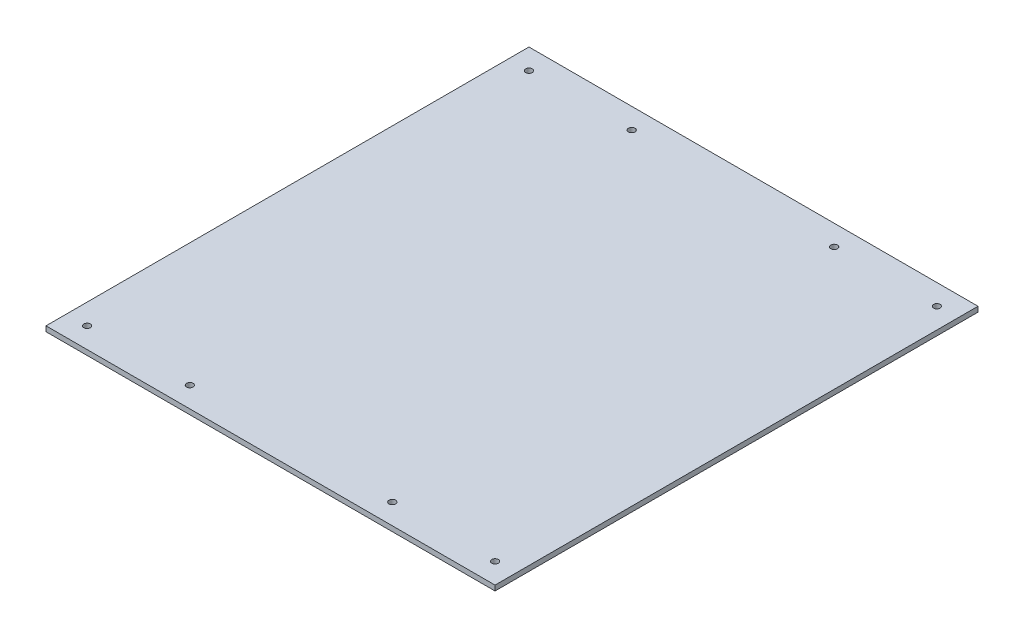
from build123d import *

# Parameters (mm, degrees)
SKETCH1_W                = 437
SKETCH1_H                = 470
BOSS_EXTRUDE1_DEPTH      = 5
M6_CLEARANCE_HOLE1_D     = 6.4
M6_CLEARANCE_HOLE1_DEPTH = 10
M6_CLEARANCE_HOLE1_TIP   = 1.922753981


with BuildPart() as part:
    # Sketch1 → Boss-Extrude1 (new body)
    with BuildSketch(Plane(origin=(0, 0, 0), x_dir=(1, 0, 0), z_dir=(0, 1, 0))):
        Rectangle(SKETCH1_W, SKETCH1_H)
    extrude(amount=BOSS_EXTRUDE1_DEPTH)

    # M6 Clearance Hole1
    with Locations(Plane(origin=(0, 5, 0), x_dir=(1, 0, 0), z_dir=(0, 1, 0))):
        with Locations((-198.5, 215), (-98.5, 215), (98.5, 215), (198.5, 215), (-198.5, -215), (-98.5, -215), (98.5, -215), (198.5, -215)):
            Hole(M6_CLEARANCE_HOLE1_D / 2, depth=M6_CLEARANCE_HOLE1_DEPTH)
            with Locations((0, 0, -(M6_CLEARANCE_HOLE1_DEPTH + M6_CLEARANCE_HOLE1_TIP / 2))):  # 118° drill point
                Cone(0, M6_CLEARANCE_HOLE1_D / 2, M6_CLEARANCE_HOLE1_TIP, mode=Mode.SUBTRACT)


solid = part.part
